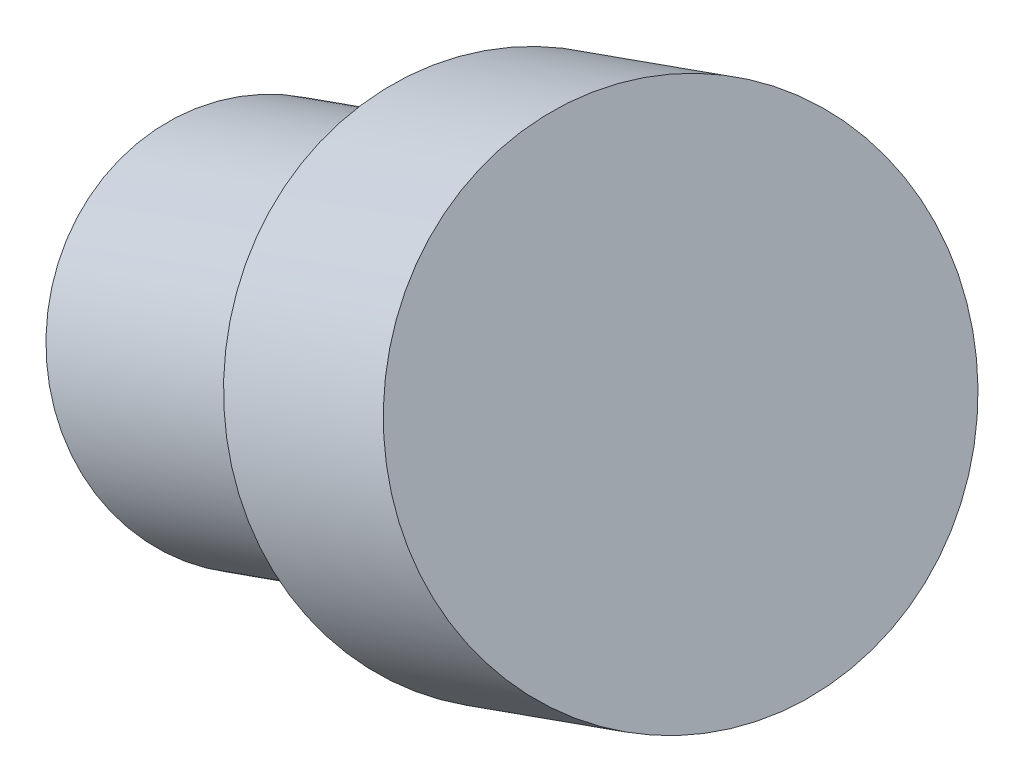
from build123d import *

# Parameters (mm, degrees)
SKETCH2_R             = 32.184938318
BOSS_EXTRUDE1_DEPTH   = 78
SKETCH3_R             = 44.452761075
BOSS_EXTRUDE2_DEPTH   = 48
BODY_MOVE_COPY2_ANGLE = 94.867085016


with BuildPart() as part:
    # Sketch2 → Boss-Extrude1 (new body)
    with BuildSketch(Plane(origin=(0, 0, 0), x_dir=(1, 0, 0), z_dir=(0, 1, 0))):
        Circle(SKETCH2_R)
    extrude(amount=BOSS_EXTRUDE1_DEPTH)

    # Sketch3 → Boss-Extrude2 (add)
    with BuildSketch(Plane(origin=(0, 78, 0), x_dir=(1, 0, 0), z_dir=(0, 1, 0))):
        Circle(SKETCH3_R)
    extrude(amount=BOSS_EXTRUDE2_DEPTH)


with BuildPart() as part_1:
    # Body-Move/Copy1: moved
    add(part.part.moved(Location((-72.960744445, 52.218831428, 0))))


with BuildPart() as part_2:
    # Body-Move/Copy2: moved
    add(part_1.part.moved(Location((0, 0, 0))).rotate(Axis((-95.551423715, 86.931599726, 17.334437881), (0.562837469, 0.704764727, -0.43188038)), BODY_MOVE_COPY2_ANGLE))


solid = part_2.part
